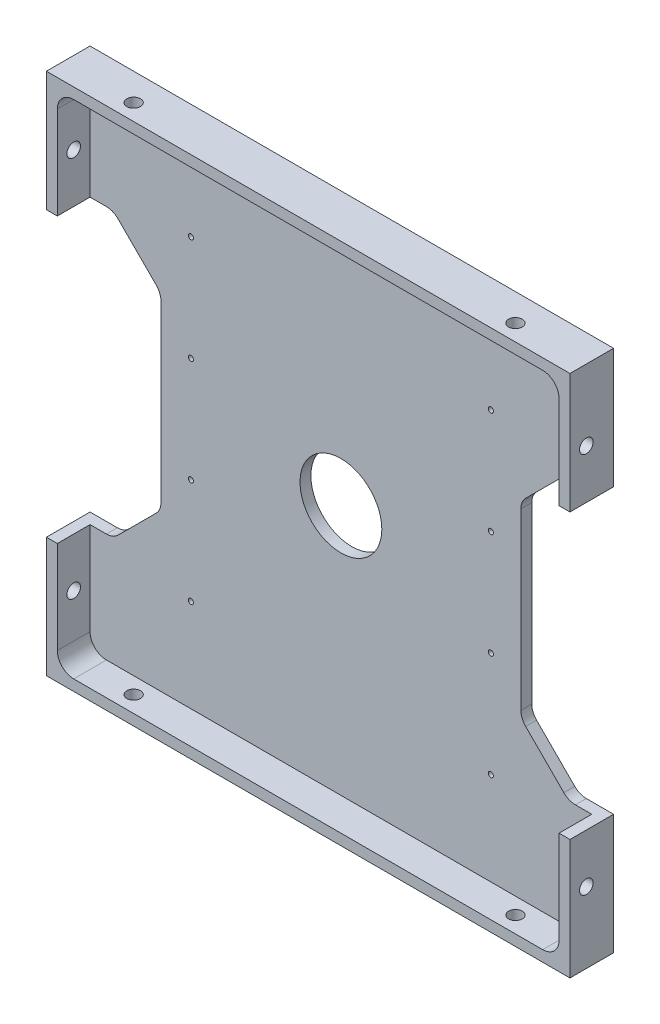
from build123d import *

# Parameters (mm, degrees)
SKETCH1_W                       = 96
SKETCH1_H                       = 96
BOSS_EXTRUDE1_DEPTH             = 8
SKETCH2_W                       = 92
SKETCH2_H                       = 92
COMPONENT_PLATFORM_DEPTH        = 6
CABLE_SLOTS_DEPTH               = 6
SKETCH4_R                       = 7.5
CENTER_MASS_CUT_DEPTH           = 6
INNER_CORNER_FILLETS_R          = 3
TAP_DRILL_FOR_M3X0_5_TAP4_D     = 2.5
TAP_DRILL_FOR_M3X0_5_TAP4_DEPTH = 2
TAP_DRILL_FOR_M1_2X0_25_TAP1_D  = 0.95
TAP_DRILL_FOR_M3X0_5_TAP3_D     = 2.5
TAP_DRILL_FOR_M3X0_5_TAP3_DEPTH = 2


with BuildPart() as part:
    # Sketch1 → Boss-Extrude1 (new body)
    with BuildSketch(Plane.XY):
        Rectangle(SKETCH1_W, SKETCH1_H)
    extrude(amount=BOSS_EXTRUDE1_DEPTH)

    # Sketch2 → Component Platform (cut)
    with BuildSketch(Plane.XY.offset(8)):
        Rectangle(SKETCH2_W, SKETCH2_H)
    extrude(amount=-COMPONENT_PLATFORM_DEPTH, mode=Mode.SUBTRACT)

    # Sketch3 → Cable Slots (cut, symmetric)
    with BuildSketch(Plane.XY.offset(2)):
        with BuildLine():
            Line((-40.878679656, -25.121320344), (-33.878679656, -18.121320344))
            ThreePointArc((-33.878679656, -18.121320344), (-33.228361402, -17.148050297), (-33, -16))
            Line((-33, -16), (-33, 16))
            ThreePointArc((-33, 16), (-33.228361402, 17.148050297), (-33.878679656, 18.121320344))
            Line((-33.878679656, 18.121320344), (-40.878679656, 25.121320344))
            ThreePointArc((-40.878679656, 25.121320344), (-41.851949703, 25.771638598), (-43, 26))
            Line((-43, 26), (-48, 26))
            Line((-48, 26), (-48, -26))
            Line((-48, -26), (-43, -26))
            ThreePointArc((-43, -26), (-41.851949703, -25.771638598), (-40.878679656, -25.121320344))
        make_face()
        with BuildLine():
            Line((48, -26), (48, 26))
            Line((48, 26), (43, 26))
            ThreePointArc((43, 26), (41.851949703, 25.771638598), (40.878679656, 25.121320344))
            Line((40.878679656, 25.121320344), (33.878679656, 18.121320344))
            ThreePointArc((33.878679656, 18.121320344), (33.228361402, 17.148050297), (33, 16))
            Line((33, 16), (33, -16))
            ThreePointArc((33, -16), (33.228361402, -17.148050297), (33.878679656, -18.121320344))
            Line((33.878679656, -18.121320344), (40.878679656, -25.121320344))
            ThreePointArc((40.878679656, -25.121320344), (41.851949703, -25.771638598), (43, -26))
            Line((43, -26), (48, -26))
        make_face()
    extrude(amount=CABLE_SLOTS_DEPTH, both=True, mode=Mode.SUBTRACT)

    # Sketch4 → Center Mass Cut (cut)
    with BuildSketch(Plane.XY.offset(2)):
        Circle(SKETCH4_R)
    extrude(amount=-CENTER_MASS_CUT_DEPTH, mode=Mode.SUBTRACT)

    # Inner Corner Fillets
    inner_corner_fillets_edges = [part.edges().sort_by_distance(p)[0] for p in [
        (-46, -46, 5),
        (-46, 46, 5),
        (46, 46, 5),
        (46, -46, 5),
    ]]
    fillet(inner_corner_fillets_edges, radius=INNER_CORNER_FILLETS_R)

    # Tap Drill for M3x0.5 Tap4
    with Locations(Plane(origin=(0, -48, 0), x_dir=(-1, 0, 0), z_dir=(0, -1, 0))):
        with Locations((35, -5), (-35, -5)):
            tap_drill_for_m3x0_5_tap4 = Hole(TAP_DRILL_FOR_M3X0_5_TAP4_D / 2, depth=TAP_DRILL_FOR_M3X0_5_TAP4_DEPTH)

    # Mirror2: Tap Drill for M3x0.5 Tap4 across plane
    add(tap_drill_for_m3x0_5_tap4.mirror(Plane(origin=(0, 0, 0), x_dir=(0, 0, 1), z_dir=(0, -1, 0))), mode=Mode.SUBTRACT)

    # Tap Drill for M1.2x0.25 Tap1 (through all)
    with Locations(Plane.XY.offset(2)):
        with Locations((-27.5, 28.95), (-27.5, 9.65), (-27.5, -9.65), (-27.5, -28.95), (27.5, -28.95), (27.5, -9.65), (27.5, 9.65), (27.5, 28.95)):
            Hole(TAP_DRILL_FOR_M1_2X0_25_TAP1_D / 2)

    # Tap Drill for M3x0.5 Tap3
    with Locations(Plane(origin=(48, 0, 0), x_dir=(0, 0, -1), z_dir=(1, 0, 0))):
        with Locations((-5, -35), (-5, 35)):
            tap_drill_for_m3x0_5_tap3 = Hole(TAP_DRILL_FOR_M3X0_5_TAP3_D / 2, depth=TAP_DRILL_FOR_M3X0_5_TAP3_DEPTH)

    # Mirror3: Tap Drill for M3x0.5 Tap3 across plane
    add(tap_drill_for_m3x0_5_tap3.mirror(Plane(origin=(0, 0, 0), x_dir=(0, 0, 1), z_dir=(1, 0, 0))), mode=Mode.SUBTRACT)


solid = part.part
